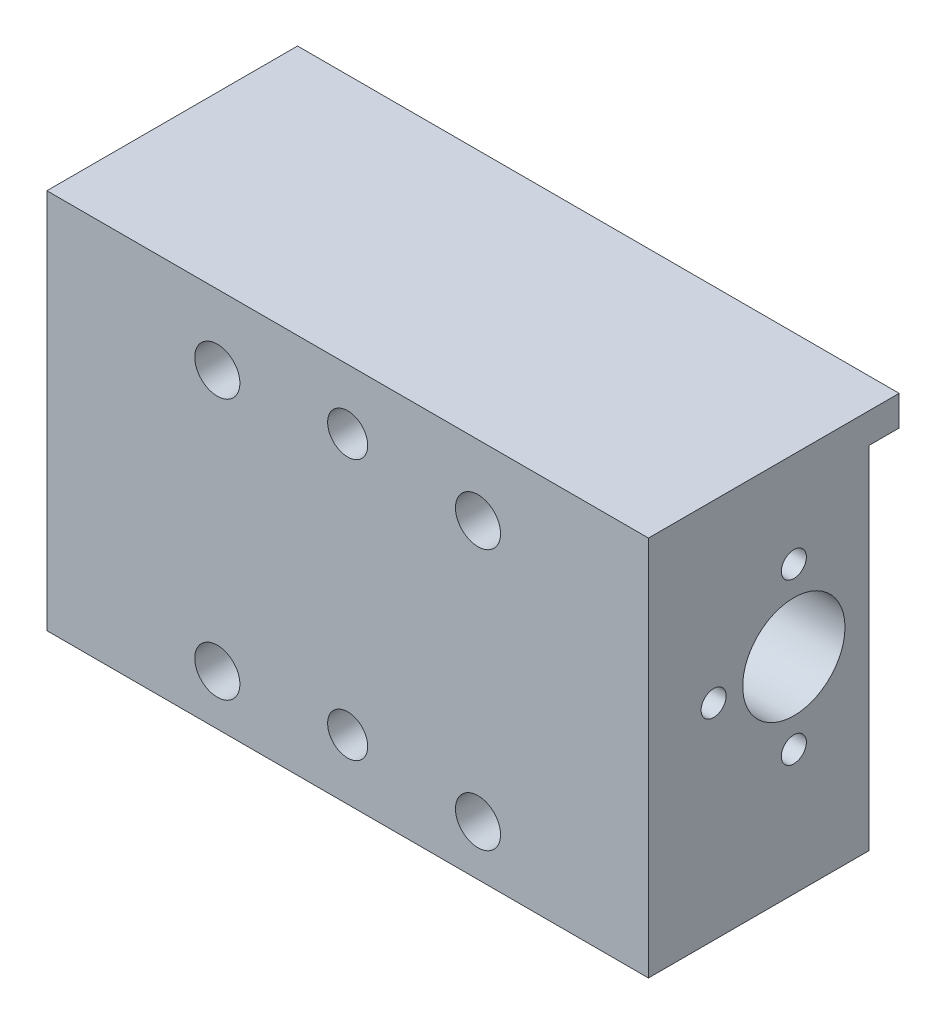
from build123d import *

# Parameters (mm, degrees)
CROQUIS1_W                         = 60
CROQUIS1_H                         = 38
SALIENTE_EXTRUIR1_DEPTH            = 22
CROQUIS2_R                         = 5.1
CORTAR_EXTRUIR1_DEPTH              = 61
TALADROS_DE_ESPIGA_DE_4_0MM2_D     = 4
TALADROS_DE_ESPIGA_DE_4_0MM2_DEPTH = 14
TALADROS_DE_ESPIGA_DE_4_0MM2_TIP   = 1.201721238
CROQUIS6_W                         = 60
CROQUIS6_H                         = 3
SALIENTE_EXTRUIR2_DEPTH            = 3
TALADRO_ROSCADO_M31_D              = 2.5
TALADRO_ROSCADO_M31_DEPTH          = 14
TALADRO_ROSCADO_M31_TIP            = 0.751075774
TALADRO_DE_MARGEN_PARA_M41_D       = 4.5


with BuildPart() as part:
    # Croquis1 → Saliente-Extruir1 (new body)
    with BuildSketch(Plane.XY):
        with Locations((30, 19)):
            Rectangle(CROQUIS1_W, CROQUIS1_H)
    extrude(amount=SALIENTE_EXTRUIR1_DEPTH)

    # Croquis2 → Cortar-Extruir1 (cut, through all)
    with BuildSketch(Plane(origin=(60, 0, 0), x_dir=(0, 0, -1), z_dir=(1, 0, 0))):
        with Locations((-7.5, 20.5)):
            Circle(CROQUIS2_R)
    extrude(amount=-CORTAR_EXTRUIR1_DEPTH, mode=Mode.SUBTRACT)

    # Taladros de espiga de Ø4.0mm2
    with Locations(Plane.XY.offset(22)):
        with Locations((30, 6), (30, 32)):
            Hole(TALADROS_DE_ESPIGA_DE_4_0MM2_D / 2, depth=TALADROS_DE_ESPIGA_DE_4_0MM2_DEPTH)
            with Locations((0, 0, -(TALADROS_DE_ESPIGA_DE_4_0MM2_DEPTH + TALADROS_DE_ESPIGA_DE_4_0MM2_TIP / 2))):  # 118° drill point
                Cone(0, TALADROS_DE_ESPIGA_DE_4_0MM2_D / 2, TALADROS_DE_ESPIGA_DE_4_0MM2_TIP, mode=Mode.SUBTRACT)

    # Croquis6 → Saliente-Extruir2 (add)
    with BuildSketch(Plane(origin=(0, 0, 0), x_dir=(-1, 0, 0), z_dir=(0, 0, -1))):
        with Locations((-30, 36.5)):
            Rectangle(CROQUIS6_W, CROQUIS6_H)
    extrude(amount=SALIENTE_EXTRUIR2_DEPTH)

    # Taladro roscado M31
    with Locations(Plane(origin=(60, 0, 0), x_dir=(0, 0, -1), z_dir=(1, 0, 0))):
        with Locations((-15.5, 20.5), (-7.5, 12.5), (-7.5, 28.5)):
            Hole(TALADRO_ROSCADO_M31_D / 2, depth=TALADRO_ROSCADO_M31_DEPTH)
            with Locations((0, 0, -(TALADRO_ROSCADO_M31_DEPTH + TALADRO_ROSCADO_M31_TIP / 2))):  # 118° drill point
                Cone(0, TALADRO_ROSCADO_M31_D / 2, TALADRO_ROSCADO_M31_TIP, mode=Mode.SUBTRACT)

    # Taladro de margen para M41 (through all)
    with Locations(Plane.XY.offset(22)):
        with Locations((43, 5), (43, 31), (17, 5), (17, 31)):
            Hole(TALADRO_DE_MARGEN_PARA_M41_D / 2)


solid = part.part
